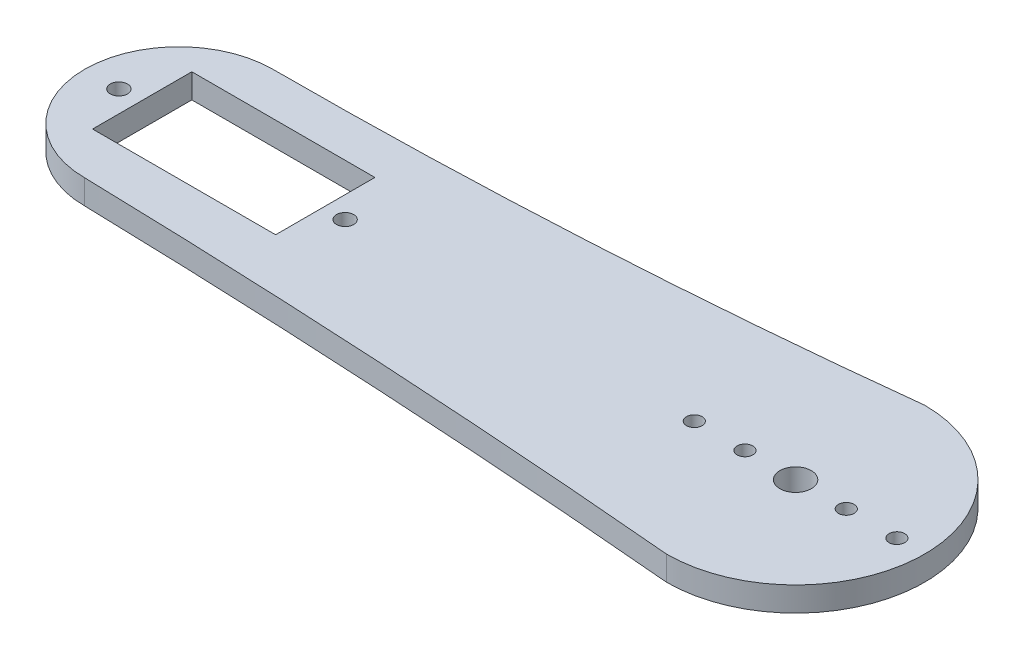
from build123d import *

# Parameters (mm, degrees)
SKETCH1_R           = 1.93023
SKETCH1_R_2         = 1.061627907
SKETCH1_R_3         = 0.965116279
SKETCH1_R_4         = 0.96512
SKETCH1_W           = 22.5
SKETCH1_H           = 12.2
BOSS_EXTRUDE1_DEPTH = 3


with BuildPart() as part:
    # Sketch1 → Boss-Extrude1 (new body)
    with BuildSketch(Plane(origin=(0, 0, 0), x_dir=(1, 0, 0), z_dir=(0, 1, 0))):
        with BuildLine():
            ThreePointArc((-66.883539, 26.379856778), (-78.440375529, 14.823020249), (-66.883539, 3.26618372))
            ThreePointArc((-66.883539, 3.26618372), (-28.9420606, 1.724738168), (8.930411, -1.033473673))
            ThreePointArc((8.930411, -1.033473673), (24.786904692, 14.823020019), (8.930411, 30.679513711))
            ThreePointArc((8.930411, 30.679513711), (-28.915651041, 27.455633961), (-66.883539, 26.379856778))
        make_face()
        with Locations((8.930411, 14.823020019)):
            Circle(SKETCH1_R, mode=Mode.SUBTRACT)
        with Locations((-74.238049948, 14.823020249)):
            Circle(SKETCH1_R_2, mode=Mode.SUBTRACT)
        with Locations((-46.438049948, 14.823020249)):
            Circle(SKETCH1_R_2, mode=Mode.SUBTRACT)
        with Locations((2.705411, 14.823020019)):
            Circle(SKETCH1_R_3, mode=Mode.SUBTRACT)
        with Locations((-3.519589, 14.823020019)):
            Circle(SKETCH1_R_3, mode=Mode.SUBTRACT)
        with Locations((15.15541, 14.82302)):
            Circle(SKETCH1_R_4, mode=Mode.SUBTRACT)
        with Locations((21.380409, 14.823020019)):
            Circle(SKETCH1_R_4, mode=Mode.SUBTRACT)
        with Locations((-60.338049948, 15.035810946)):
            Rectangle(SKETCH1_W, SKETCH1_H, mode=Mode.SUBTRACT)
    extrude(amount=BOSS_EXTRUDE1_DEPTH)


solid = part.part
